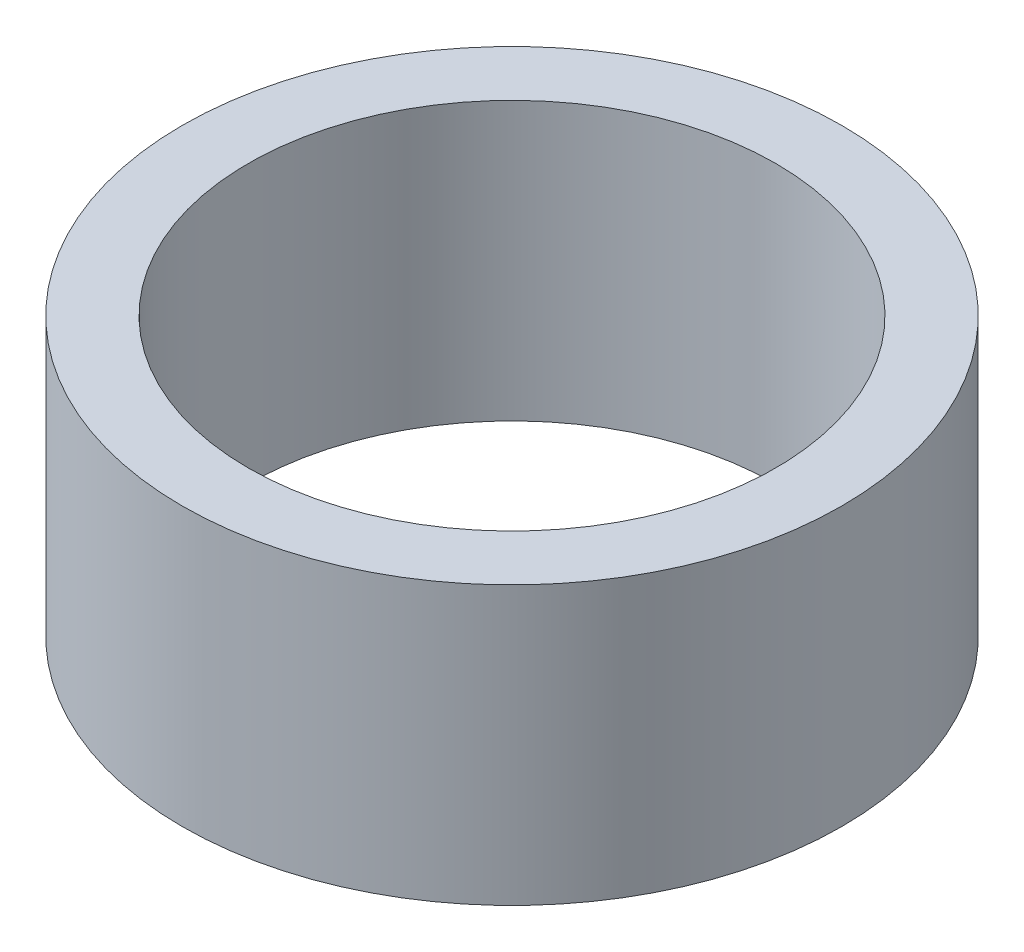
from build123d import *

# Parameters (mm, degrees)
SKETCH1_R           = 30.1625
SKETCH1_R_2         = 24.13
BOSS_EXTRUDE1_DEPTH = 25.4


with BuildPart() as part:
    # Sketch1 → Boss-Extrude1 (new body)
    with BuildSketch(Plane(origin=(0, 0, 0), x_dir=(1, 0, 0), z_dir=(0, 1, 0))):
        Circle(SKETCH1_R)
        Circle(SKETCH1_R_2, mode=Mode.SUBTRACT)
    extrude(amount=BOSS_EXTRUDE1_DEPTH)


solid = part.part
